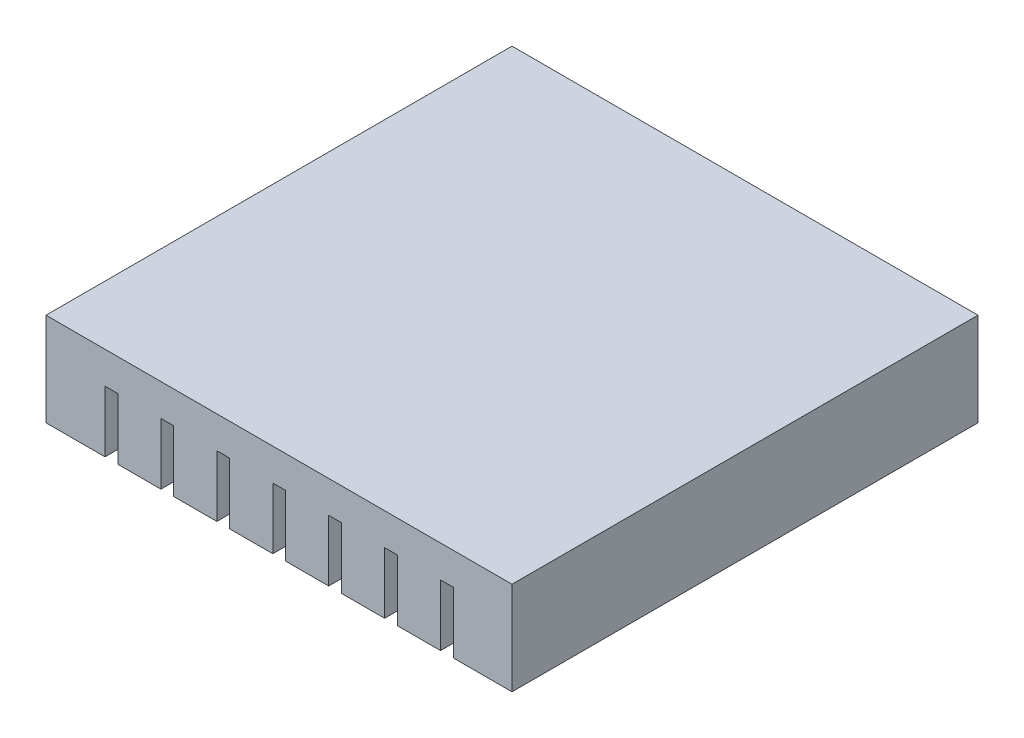
from build123d import *

# Parameters (mm, degrees)
SKETCH1_W           = 50
SKETCH1_H           = 50
BOSS_EXTRUDE1_DEPTH = 10
SKETCH3_W           = 1.37
SKETCH3_H           = 6.568764243
CUT_EXTRUDE1_DEPTH  = 50
LPATTERN1_COUNT     = 7
LPATTERN1_PITCH     = 6


with BuildPart() as part:
    # Sketch1 → Boss-Extrude1 (new body)
    with BuildSketch(Plane(origin=(0, 0, 0), x_dir=(1, 0, 0), z_dir=(0, 1, 0))):
        with Locations((25, -25)):
            Rectangle(SKETCH1_W, SKETCH1_H)
    extrude(amount=BOSS_EXTRUDE1_DEPTH)

    # Sketch3 → Cut-Extrude1 (cut)
    with BuildSketch(Plane.XY.offset(50)):
        with Locations((7.015961915, 3.284382122)):
            Rectangle(SKETCH3_W, SKETCH3_H)
    cut_extrude1 = extrude(amount=-CUT_EXTRUDE1_DEPTH, mode=Mode.SUBTRACT)

    # LPattern1: Cut-Extrude1 ×7
    with Locations(*[(i * LPATTERN1_PITCH, 0, 0) for i in range(1, LPATTERN1_COUNT)]):
        add(cut_extrude1, mode=Mode.SUBTRACT)


solid = part.part
